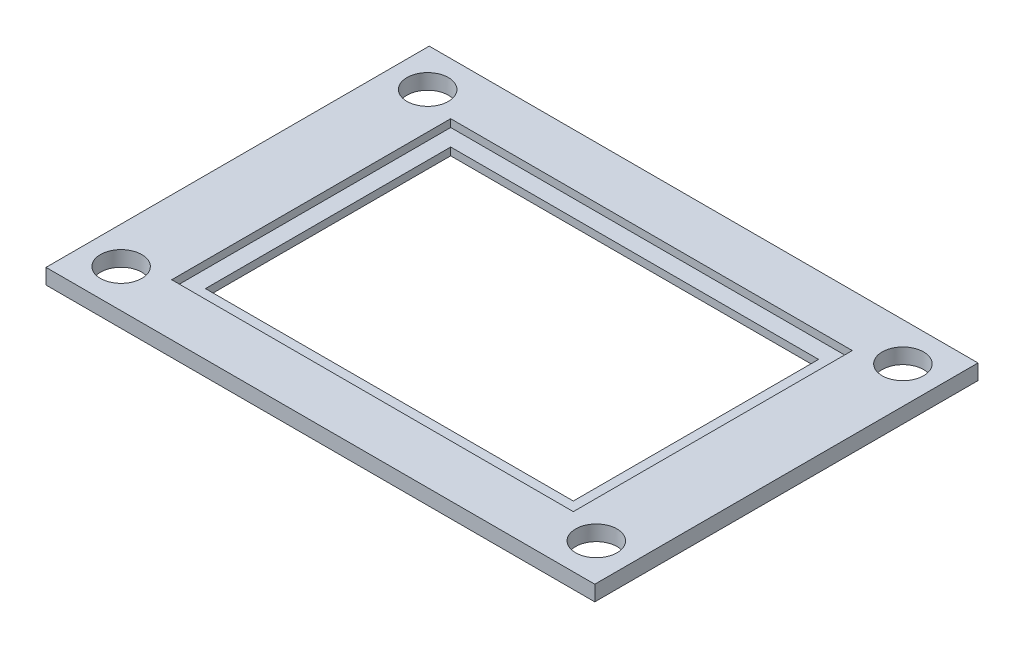
from build123d import *

# Parameters (mm, degrees)
SKETCH1_W           = 35.8
SKETCH1_H           = 25
SKETCH1_W_2         = 24
SKETCH1_H_2         = 16
BOSS_EXTRUDE1_DEPTH = 1
SKETCH2_W           = 26.2
SKETCH2_H           = 18.2
CUT_EXTRUDE1_DEPTH  = 0.5
CUT_EXTRUDE2_REACH  = 3
SKETCH3_R           = 1.35


with BuildPart() as part:
    # Sketch1 → Boss-Extrude1 (new body)
    with BuildSketch(Plane(origin=(0, 0, 0), x_dir=(1, 0, 0), z_dir=(0, 1, 0))):
        Rectangle(SKETCH1_W, SKETCH1_H)
        Rectangle(SKETCH1_W_2, SKETCH1_H_2, mode=Mode.SUBTRACT)
    extrude(amount=BOSS_EXTRUDE1_DEPTH)

    # Sketch2 → Cut-Extrude1 (cut)
    with BuildSketch(Plane(origin=(0, 1, 0), x_dir=(1, 0, 0), z_dir=(0, 1, 0))):
        Rectangle(SKETCH2_W, SKETCH2_H)
    extrude(amount=-CUT_EXTRUDE1_DEPTH, mode=Mode.SUBTRACT)

    # Sketch3 → Cut-Extrude2 (cut, up to next)
    with BuildSketch(Plane(origin=(0, 1, 0), x_dir=(1, 0, 0), z_dir=(0, 1, 0)), mode=Mode.PRIVATE) as cut_extrude2_sk1:
        with Locations((-15.5, 10)):
            Circle(SKETCH3_R)
    cut_extrude2_tool1 = extrude(cut_extrude2_sk1.sketch, amount=-CUT_EXTRUDE2_REACH, mode=Mode.PRIVATE) & part.part
    add(cut_extrude2_tool1.solids().sort_by_distance((-15.5, 1, -10))[0], mode=Mode.SUBTRACT)
    # Sketch3 → Cut-Extrude2 (cut, up to next)
    with BuildSketch(Plane(origin=(0, 1, 0), x_dir=(1, 0, 0), z_dir=(0, 1, 0)), mode=Mode.PRIVATE) as cut_extrude2_sk2:
        with Locations((-15.5, -10)):
            Circle(SKETCH3_R)
    cut_extrude2_tool2 = extrude(cut_extrude2_sk2.sketch, amount=-CUT_EXTRUDE2_REACH, mode=Mode.PRIVATE) & part.part
    add(cut_extrude2_tool2.solids().sort_by_distance((-15.5, 1, 10))[0], mode=Mode.SUBTRACT)
    # Sketch3 → Cut-Extrude2 (cut, up to next)
    with BuildSketch(Plane(origin=(0, 1, 0), x_dir=(1, 0, 0), z_dir=(0, 1, 0)), mode=Mode.PRIVATE) as cut_extrude2_sk3:
        with Locations((15.5, -10)):
            Circle(SKETCH3_R)
    cut_extrude2_tool3 = extrude(cut_extrude2_sk3.sketch, amount=-CUT_EXTRUDE2_REACH, mode=Mode.PRIVATE) & part.part
    add(cut_extrude2_tool3.solids().sort_by_distance((15.5, 1, 10))[0], mode=Mode.SUBTRACT)
    # Sketch3 → Cut-Extrude2 (cut, up to next)
    with BuildSketch(Plane(origin=(0, 1, 0), x_dir=(1, 0, 0), z_dir=(0, 1, 0)), mode=Mode.PRIVATE) as cut_extrude2_sk4:
        with Locations((15.5, 10)):
            Circle(SKETCH3_R)
    cut_extrude2_tool4 = extrude(cut_extrude2_sk4.sketch, amount=-CUT_EXTRUDE2_REACH, mode=Mode.PRIVATE) & part.part
    add(cut_extrude2_tool4.solids().sort_by_distance((15.5, 1, -10))[0], mode=Mode.SUBTRACT)


solid = part.part
